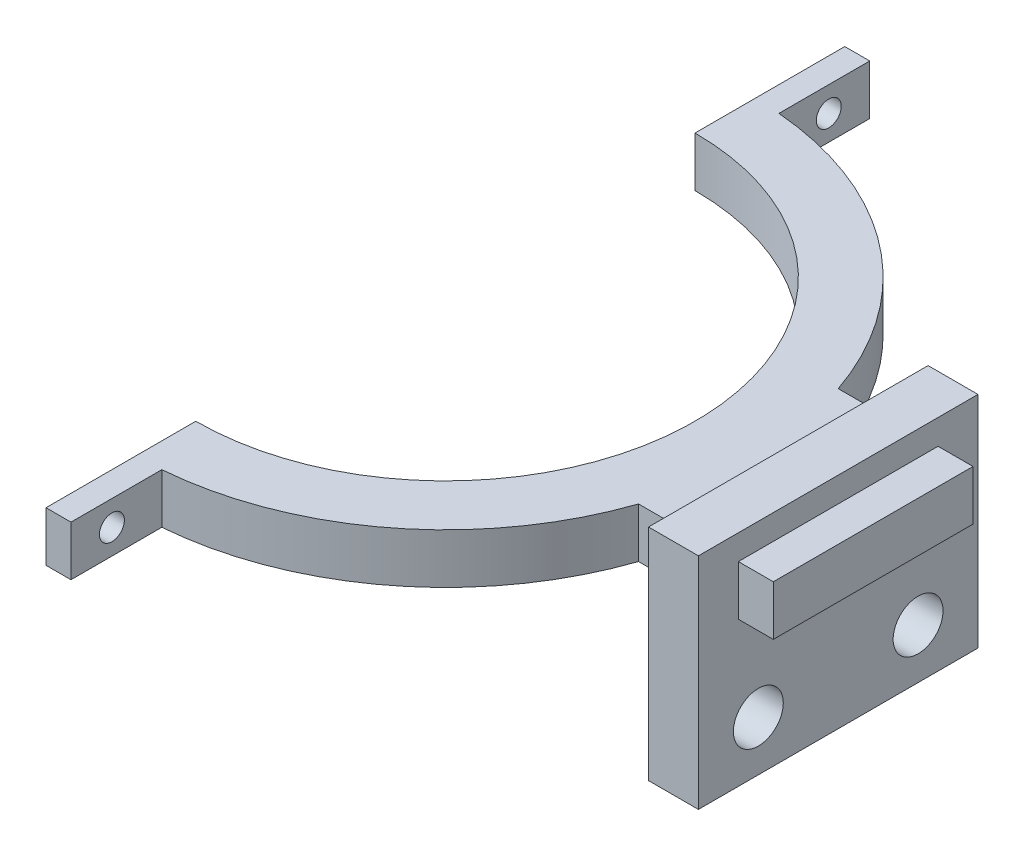
from build123d import *

# Parameters (mm, degrees)
BOSS_EXTRUDE1_DEPTH = 5
SKETCH4_W           = 28
SKETCH4_H           = 22
SKETCH4_R           = 2.5
BOSS_EXTRUDE3_DEPTH = 5
SKETCH6_W           = 20
SKETCH6_H           = 5
BOSS_EXTRUDE4_DEPTH = 3.5
SKETCH8_R           = 1.25
CUT_EXTRUDE1_DEPTH  = 3.5


with BuildPart() as part:
    # Sketch1 → Boss-Extrude1 (new body)
    with BuildSketch(Plane(origin=(0, 0, 0), x_dir=(1, 0, 0), z_dir=(0, 1, 0))):
        with BuildLine():
            Line((0, -25), (0, -40))
            Line((0, -40), (2.5, -40))
            Line((2.5, -40), (2.5, -30.899029111))
            ThreePointArc((2.5, -30.899029111), (19.044247329, -24.460511926), (29.342801502, -10))
            Line((29.342801502, -10), (39.342801502, -10))
            Line((39.342801502, -10), (39.342801502, 10))
            Line((39.342801502, 10), (29.342801502, 10))
            ThreePointArc((29.342801502, 10), (19.044247329, 24.460511926), (2.5, 30.899029111))
            Line((2.5, 30.899029111), (2.5, 40))
            Line((2.5, 40), (0, 40))
            Line((0, 40), (0, 25))
            ThreePointArc((0, 25), (25, 0), (0, -25))
        make_face()
    extrude(amount=BOSS_EXTRUDE1_DEPTH)

    # Sketch4 → Boss-Extrude3 (add)
    with BuildSketch(Plane(origin=(39.342801502, 0, 0), x_dir=(0, 0, -1), z_dir=(1, 0, 0))):
        with Locations((0, -3.5)):
            Rectangle(SKETCH4_W, SKETCH4_H)
        with Locations((8, -9.5)):
            Circle(SKETCH4_R, mode=Mode.SUBTRACT)
        with Locations((-8, -9.5)):
            Circle(SKETCH4_R, mode=Mode.SUBTRACT)
    extrude(amount=-BOSS_EXTRUDE3_DEPTH)

    # Sketch6 → Boss-Extrude4 (add)
    with BuildSketch(Plane(origin=(39.342801502, 0, 0), x_dir=(0, 0, -1), z_dir=(1, 0, 0))):
        with Locations((0, 2.5)):
            Rectangle(SKETCH6_W, SKETCH6_H)
    extrude(amount=BOSS_EXTRUDE4_DEPTH)

    # Sketch8 → Cut-Extrude1 (cut, through all)
    with BuildSketch(Plane(origin=(2.5, 0, 0), x_dir=(0, 0, -1), z_dir=(1, 0, 0))):
        with Locations((-35.899029111, 2.5)):
            Circle(SKETCH8_R)
        with Locations((35.899029111, 2.5)):
            Circle(SKETCH8_R)
    extrude(amount=-CUT_EXTRUDE1_DEPTH, mode=Mode.SUBTRACT)


solid = part.part
